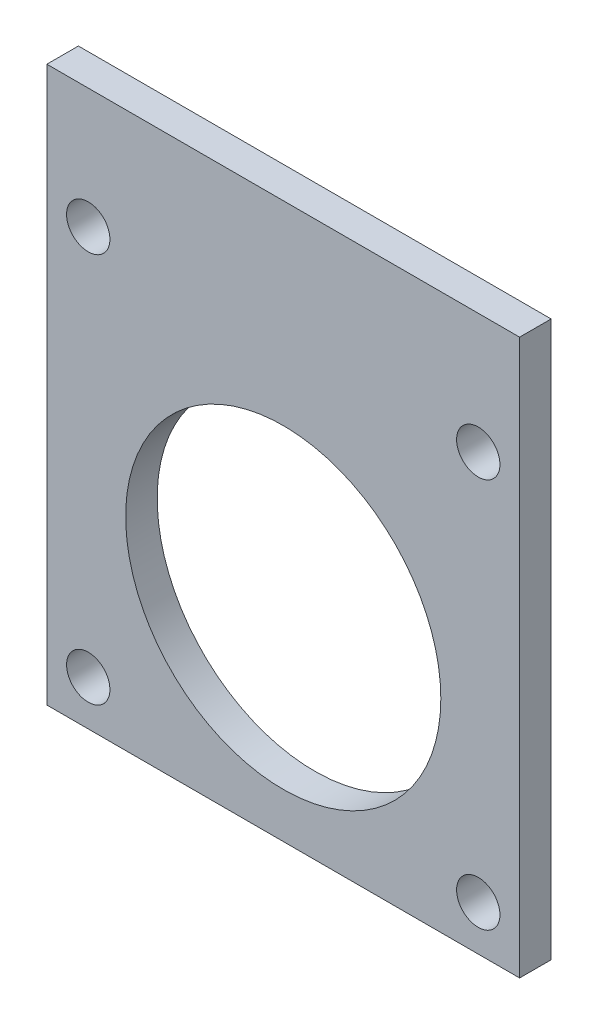
from build123d import *

# Parameters (mm, degrees)
SKETCH_1_W          = 60
SKETCH_1_H          = 60.44
SKETCH_1_R          = 2.75
EXTRUDE_1_DEPTH     = 4
SKETCH_3_R          = 20
CUT_EXTRUDE_1_DEPTH = 5
SKETCH_6_W          = 60
SKETCH_6_H          = 4
EXTRUDE_2_DEPTH     = 10


with BuildPart() as part:
    # 草圖1 → 填料-伸長1 (new body)
    with BuildSketch(Plane.XY):
        with Locations((30, -30.22)):
            Rectangle(SKETCH_1_W, SKETCH_1_H)
        with Locations((5.25, -5.25)):
            Circle(SKETCH_1_R, mode=Mode.SUBTRACT)
        with Locations((54.75, -5.25)):
            Circle(SKETCH_1_R, mode=Mode.SUBTRACT)
        with Locations((5.25, -54.75)):
            Circle(SKETCH_1_R, mode=Mode.SUBTRACT)
        with Locations((54.75, -54.75)):
            Circle(SKETCH_1_R, mode=Mode.SUBTRACT)
    extrude(amount=EXTRUDE_1_DEPTH)

    # 草圖3 → 除料-伸長1 (cut, through all)
    with BuildSketch(Plane.XY.offset(4)):
        with Locations((30, -34.716194978)):
            Circle(SKETCH_3_R)
    extrude(amount=-CUT_EXTRUDE_1_DEPTH, mode=Mode.SUBTRACT)

    # 草圖6 → 填料-伸長2 (add)
    with BuildSketch(Plane(origin=(0, 0, 0), x_dir=(1, 0, 0), z_dir=(0, 1, 0))):
        with Locations((30, -2)):
            Rectangle(SKETCH_6_W, SKETCH_6_H)
    extrude(amount=EXTRUDE_2_DEPTH)


solid = part.part
